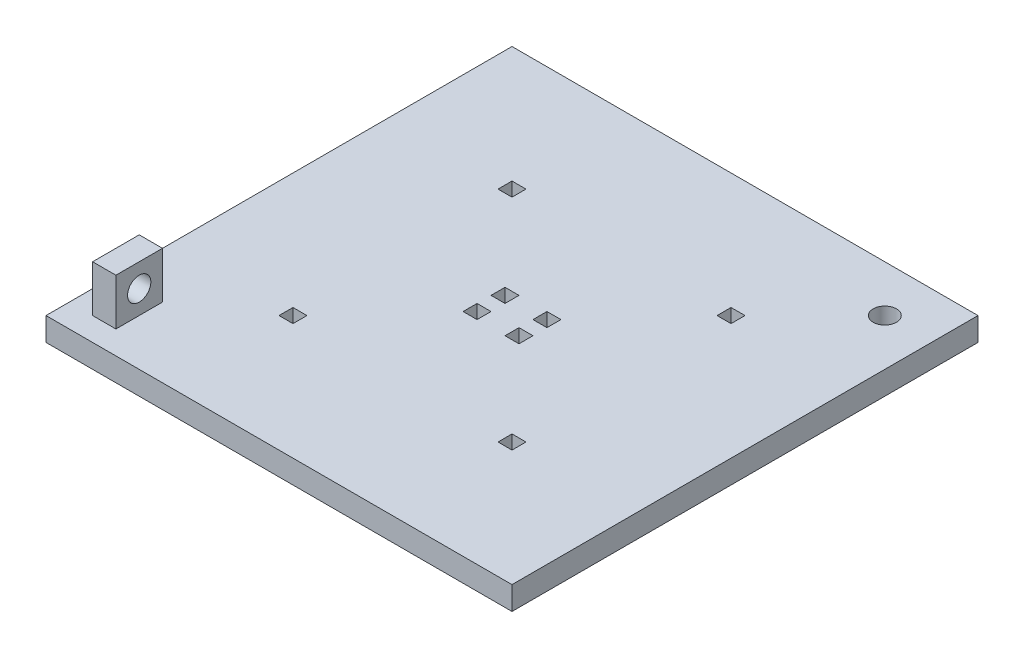
from build123d import *

# Parameters (mm, degrees)
SKETCH1_W           = 100
SKETCH1_H           = 100
SKETCH1_R           = 2.5
SKETCH1_W_2         = 3
SKETCH1_H_2         = 3
BOSS_EXTRUDE1_DEPTH = 5
SKETCH4_W           = 5
SKETCH4_H           = 10
BOSS_EXTRUDE2_DEPTH = 10
SKETCH5_R           = 2.5
CUT_EXTRUDE1_DEPTH  = 15


with BuildPart() as part:
    # Sketch1 → Boss-Extrude1 (new body)
    with BuildSketch(Plane(origin=(0, 0, 0), x_dir=(1, 0, 0), z_dir=(0, 1, 0))):
        Rectangle(SKETCH1_W, SKETCH1_H)
        with Locations((40, 40)):
            Circle(SKETCH1_R, mode=Mode.SUBTRACT)
        with Locations((-23.5, 23.5)):
            Rectangle(SKETCH1_W_2, SKETCH1_H_2, mode=Mode.SUBTRACT)
        with Locations((23.5, 23.5)):
            Rectangle(SKETCH1_W_2, SKETCH1_H_2, mode=Mode.SUBTRACT)
        with Locations((23.5, -23.5)):
            Rectangle(SKETCH1_W_2, SKETCH1_H_2, mode=Mode.SUBTRACT)
        with Locations((-23.5, -23.5)):
            Rectangle(SKETCH1_W_2, SKETCH1_H_2, mode=Mode.SUBTRACT)
        with Locations((4.5, 3)):
            Rectangle(SKETCH1_W_2, SKETCH1_H_2, mode=Mode.SUBTRACT)
        with Locations((-4.5, 3)):
            Rectangle(SKETCH1_W_2, SKETCH1_H_2, mode=Mode.SUBTRACT)
        with Locations((4.5, -3)):
            Rectangle(SKETCH1_W_2, SKETCH1_H_2, mode=Mode.SUBTRACT)
        with Locations((-4.5, -3)):
            Rectangle(SKETCH1_W_2, SKETCH1_H_2, mode=Mode.SUBTRACT)
    extrude(amount=BOSS_EXTRUDE1_DEPTH)

    # Sketch4 → Boss-Extrude2 (add)
    with BuildSketch(Plane(origin=(0, 5, 0), x_dir=(1, 0, 0), z_dir=(0, 1, 0))):
        with Locations((-42.5, -40)):
            Rectangle(SKETCH4_W, SKETCH4_H)
    extrude(amount=BOSS_EXTRUDE2_DEPTH)

    # Sketch5 → Cut-Extrude1 (cut)
    with BuildSketch(Plane.ZY.offset(45)):
        with Locations((40, 10)):
            Circle(SKETCH5_R)
    extrude(amount=-CUT_EXTRUDE1_DEPTH, mode=Mode.SUBTRACT)


solid = part.part
